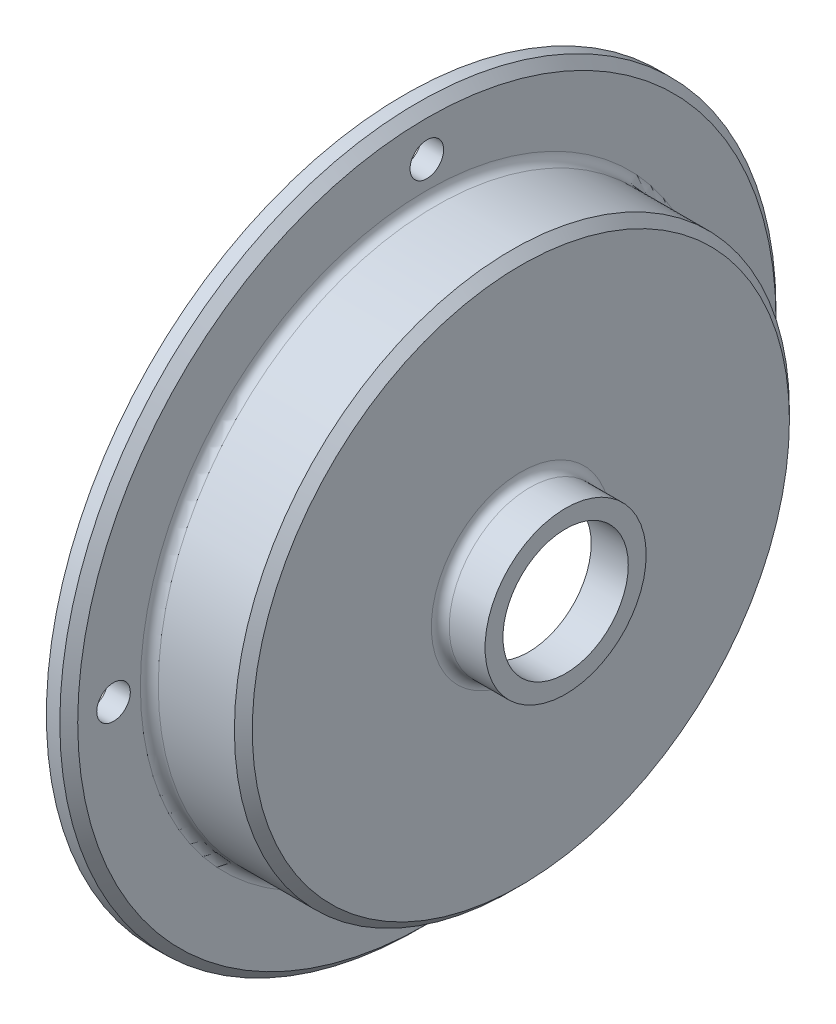
from build123d import *

# Parameters (mm, degrees)
FILLET1_R                          = 1.27
SKETCH3_R                          = 39.37
SKETCH3_R_2                        = 11.43
CUT_EXTRUDE1_DEPTH                 = 6.35
CHAMFER1_SIZE                      = 1.27
FILLET2_R                          = 1.27
F_3_16_0_1875_DIAMETER_HOLE1_D     = 4.7625
F_3_16_0_1875_DIAMETER_HOLE1_DEPTH = 13.97
F_3_16_0_1875_DIAMETER_HOLE1_TIP   = 1.430799349


with BuildPart() as part:
    # Sketch1 → Revolve1 (revolve)
    with BuildSketch(Plane.XY):
        Polygon((-17.49338415, -39.37), (-17.49338415, -50.8), (-14.31838415, -50.8), (-14.31838415, -39.37), (5.36661585, -39.37), (5.36661585, -8.89), (0.104252055, -8.89), align=None)
    revolve(axis=Axis((18.935801868, 0, 0), (-1, 0, 0)))

    # Fillet1
    fillet1_edges = [part.edges().sort_by_distance(p)[0] for p in [
        (-14.31838415, 39.37, 0),
    ]]
    fillet(fillet1_edges, radius=FILLET1_R)

    # Sketch3 → Cut-Extrude1 (cut)
    with BuildSketch(Plane(origin=(5.36661585, 0, 0), x_dir=(0, 0, -1), z_dir=(1, 0, 0))):
        Circle(SKETCH3_R)
        Circle(SKETCH3_R_2, mode=Mode.SUBTRACT)
    extrude(amount=-CUT_EXTRUDE1_DEPTH, mode=Mode.SUBTRACT)

    # Chamfer1
    chamfer1_edges = [part.edges().sort_by_distance(p)[0] for p in [
        (-0.98338415, 39.37, 0),
        (-14.31838415, 50.8, 0),
    ]]
    chamfer(chamfer1_edges, length=CHAMFER1_SIZE)

    # Fillet2
    fillet2_edges = [part.edges().sort_by_distance(p)[0] for p in [
        (-0.98338415, 0, 11.43),
    ]]
    fillet(fillet2_edges, radius=FILLET2_R)

    # 3/16 (0.1875) Diameter Hole1
    with Locations(Plane.ZY.offset(17.49338415)):
        with Locations((-44.45, 0), (0, 44.45), (44.45, 0), (0, -44.45)):
            Hole(F_3_16_0_1875_DIAMETER_HOLE1_D / 2, depth=F_3_16_0_1875_DIAMETER_HOLE1_DEPTH)
            with Locations((0, 0, -(F_3_16_0_1875_DIAMETER_HOLE1_DEPTH + F_3_16_0_1875_DIAMETER_HOLE1_TIP / 2))):  # 118° drill point
                Cone(0, F_3_16_0_1875_DIAMETER_HOLE1_D / 2, F_3_16_0_1875_DIAMETER_HOLE1_TIP, mode=Mode.SUBTRACT)


solid = part.part
